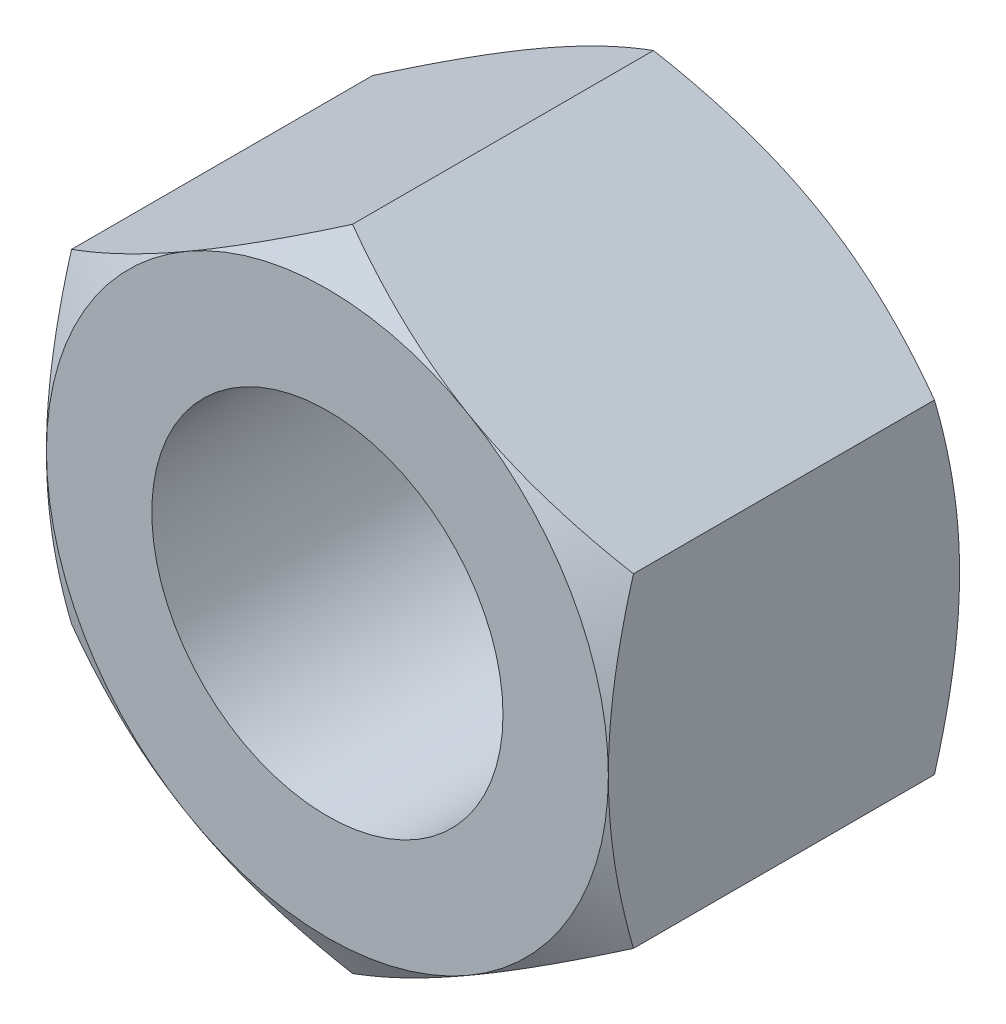
from build123d import *

# Parameters (mm, degrees)
BOSS_EXTRU_1_DEPTH      = 5
ENL_V_MAT_EXTRU_1_REACH = 7
ESQUISSE2_R             = 2.5


with BuildPart() as part:
    # Esquisse1 → Boss.-Extru.1 (new body)
    with BuildSketch(Plane.XY):
        Polygon((0, 4.618802154), (-4, 2.309401077), (-4, -2.309401077), (0, -4.618802154), (4, -2.309401077), (4, 2.309401077), align=None)
    extrude(amount=BOSS_EXTRU_1_DEPTH)

    # Esquisse2 → Enlèv. mat.-Extru.1 (cut, up to next)
    with BuildSketch(Plane.XY.offset(5), mode=Mode.PRIVATE) as enl_v_mat_extru_1_sk1:
        Circle(ESQUISSE2_R)
    enl_v_mat_extru_1_tool1 = extrude(enl_v_mat_extru_1_sk1.sketch, amount=-ENL_V_MAT_EXTRU_1_REACH, mode=Mode.PRIVATE) & part.part
    add(enl_v_mat_extru_1_tool1.solids().sort_by_distance((0, 0, 5))[0], mode=Mode.SUBTRACT)

    # Esquisse4 → Enlèvement de matière-Révolution8 (revolve, cut)
    with BuildSketch(Plane(origin=(0, 0, 0), x_dir=(1, 0, 0), z_dir=(0, 1, 0))):
        Polygon((-8.330127019, -2.5), (-2.267949192, 1), (-9.330127019, 1), (-9.330127019, -6), (-2.267949192, -6), align=None)
    revolve(axis=Axis((0, 0, 0), (0, 0, 1)), mode=Mode.SUBTRACT)


solid = part.part
